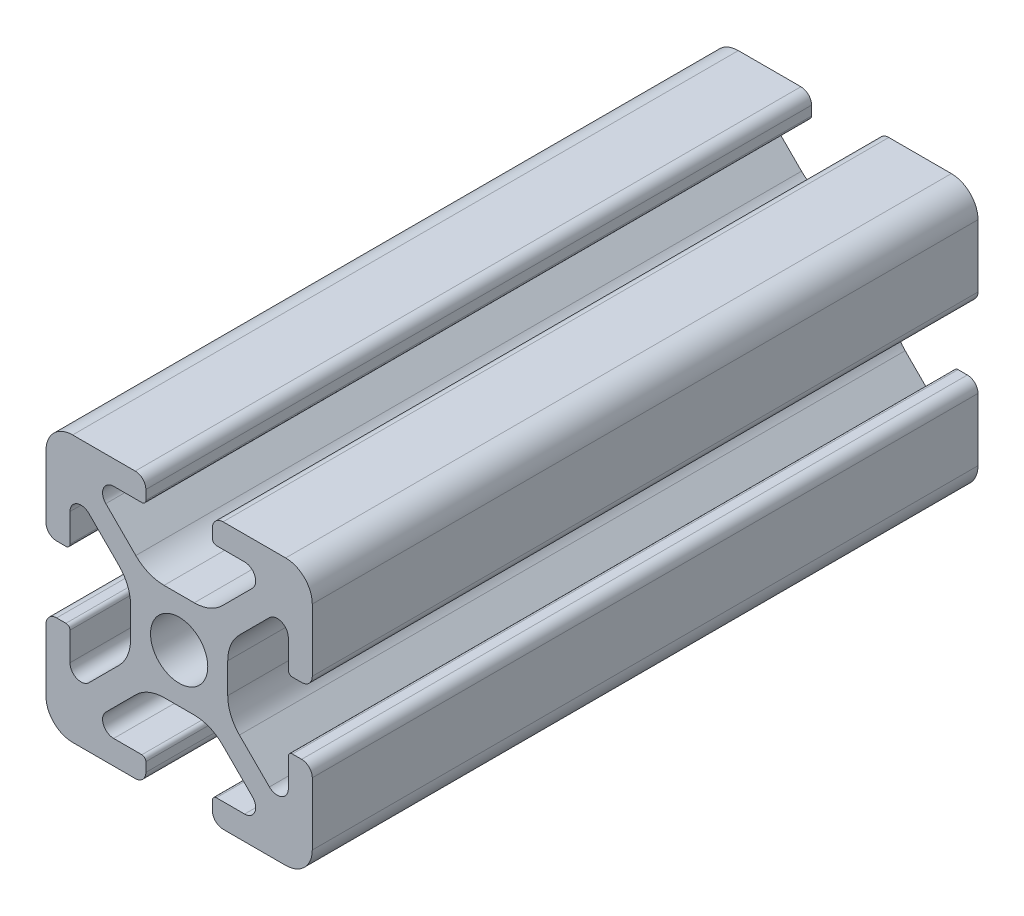
from build123d import *

# Parameters (mm, degrees)
SKETCH1_R           = 2.15
BOSS_EXTRUDE1_DEPTH = 50


with BuildPart() as part:
    # Sketch1 → Boss-Extrude1 (new body)
    with BuildSketch(Plane(origin=(0, 0, 0), x_dir=(-1, 0, 0), z_dir=(0, 0, -1))):
        with BuildLine():
            Line((-12.499999997, 0.800000003), (-12.499999998, 1.500000003))
            ThreePointArc((-12.499999998, 1.500000003), (-12.587867964, 1.712132039), (-12.8, 1.800000005))
            Line((-12.8, 1.800000005), (-14.9175884, 1.800000005))
            ThreePointArc((-14.9175884, 1.800000005), (-15.686636445, 2.313861481), (-15.506192291, 3.221015502))
            Line((-15.506192291, 3.221015502), (-13.255887451, 5.471320342))
            ThreePointArc((-13.255887451, 5.471320342), (-12.282617405, 6.121638595), (-11.134567109, 6.349999998))
            Line((-11.134567109, 6.349999998), (-8.865432906, 6.349999998))
            ThreePointArc((-8.865432906, 6.349999998), (-7.717382611, 6.121638596), (-6.744112565, 5.471320342))
            Line((-6.744112565, 5.471320342), (-4.493807727, 3.221015504))
            ThreePointArc((-4.493807727, 3.221015504), (-4.313363573, 2.313861481), (-5.082411619, 1.800000005))
            Line((-5.082411619, 1.800000005), (-7.20000001, 1.800000005))
            ThreePointArc((-7.20000001, 1.800000005), (-7.412132045, 1.71213204), (-7.50000001, 1.500000005))
            Line((-7.50000001, 1.500000005), (-7.50000001, 0.8))
            ThreePointArc((-7.50000001, 0.8), (-7.265685435, 0.234314575), (-6.70000001, 0))
            Line((-6.70000001, 0), (-2, 0))
            ThreePointArc((-2, 0), (-0.585786438, 0.585786438), (0, 2))
            Line((0, 2), (0, 6.699999998))
            ThreePointArc((0, 6.699999998), (-0.234314576, 7.265685424), (-0.800000003, 7.5))
            Line((-0.800000003, 7.5), (-1.500000007, 7.5))
            ThreePointArc((-1.500000007, 7.5), (-1.712132044, 7.412132033), (-1.80000001, 7.199999997))
            Line((-1.80000001, 7.199999997), (-1.80000001, 5.082411604))
            ThreePointArc((-1.80000001, 5.082411604), (-2.313861485, 4.313363559), (-3.221015507, 4.493807713))
            Line((-3.221015507, 4.493807713), (-5.471320347, 6.744112553))
            ThreePointArc((-5.471320347, 6.744112553), (-6.1216386, 7.717382599), (-6.350000003, 8.865432896))
            Line((-6.350000003, 8.865432896), (-6.350000003, 11.134567105))
            ThreePointArc((-6.350000003, 11.134567105), (-6.121638601, 12.2826174), (-5.471320347, 13.255887446))
            Line((-5.471320347, 13.255887446), (-3.221015511, 15.506192282))
            ThreePointArc((-3.221015511, 15.506192282), (-2.313861487, 15.686636436), (-1.80000001, 14.917588389))
            Line((-1.80000001, 14.917588389), (-1.80000001, 12.799999998))
            ThreePointArc((-1.80000001, 12.799999998), (-1.712132045, 12.587867963), (-1.50000001, 12.499999997))
            Line((-1.50000001, 12.499999997), (-0.8, 12.499999997))
            ThreePointArc((-0.8, 12.499999997), (-0.234314575, 12.734314573), (0, 13.299999998))
            Line((0, 13.299999998), (0, 18))
            ThreePointArc((0, 18), (-0.585786438, 19.414213562), (-2, 20))
            Line((-2, 20), (-6.700000008, 20))
            ThreePointArc((-6.700000008, 20), (-7.265685435, 19.765685424), (-7.50000001, 19.199999998))
            Line((-7.50000001, 19.199999998), (-7.50000001, 18.500000005))
            ThreePointArc((-7.50000001, 18.500000005), (-7.412132044, 18.287867969), (-7.200000008, 18.200000003))
            Line((-7.200000008, 18.200000003), (-5.082411595, 18.200000003))
            ThreePointArc((-5.082411595, 18.200000003), (-4.313363547, 17.686138525), (-4.493807702, 16.7789845))
            Line((-4.493807702, 16.7789845), (-6.744112543, 14.528679659))
            ThreePointArc((-6.744112543, 14.528679659), (-7.717382589, 13.878361405), (-8.865432885, 13.650000003))
            Line((-8.865432885, 13.650000003), (-11.134567111, 13.650000003))
            ThreePointArc((-11.134567111, 13.650000003), (-12.282617406, 13.878361405), (-13.255887452, 14.528679658))
            Line((-13.255887452, 14.528679658), (-15.506192292, 16.778984498))
            ThreePointArc((-15.506192292, 16.778984498), (-15.686636447, 17.686138525), (-14.917588397, 18.200000002))
            Line((-14.917588397, 18.200000002), (-12.799999998, 18.200000003))
            ThreePointArc((-12.799999998, 18.200000003), (-12.587867963, 18.287867968), (-12.499999997, 18.500000002))
            Line((-12.499999997, 18.500000002), (-12.499999997, 19.2))
            ThreePointArc((-12.499999997, 19.2), (-12.734314573, 19.765685425), (-13.299999998, 20))
            Line((-13.299999998, 20), (-18, 20))
            ThreePointArc((-18, 20), (-19.414213562, 19.414213562), (-20, 18))
            Line((-20, 18), (-20, 13.3))
            ThreePointArc((-20, 13.3), (-19.765685424, 12.734314573), (-19.199999998, 12.499999997))
            Line((-19.199999998, 12.499999997), (-18.500000003, 12.499999997))
            ThreePointArc((-18.500000003, 12.499999997), (-18.287867967, 12.587867964), (-18.2, 12.8))
            Line((-18.2, 12.8), (-18.2, 14.91758839))
            ThreePointArc((-18.2, 14.91758839), (-17.686138525, 15.686636435), (-16.778984504, 15.506192281))
            Line((-16.778984504, 15.506192281), (-14.528679657, 13.255887434))
            ThreePointArc((-14.528679657, 13.255887434), (-13.878361403, 12.282617388), (-13.65, 11.134567091))
            Line((-13.65, 11.134567091), (-13.65, 8.865432887))
            ThreePointArc((-13.65, 8.865432887), (-13.878361403, 7.717382591), (-14.528679656, 6.744112546))
            Line((-14.528679656, 6.744112546), (-16.778984496, 4.493807706))
            ThreePointArc((-16.778984496, 4.493807706), (-17.686138522, 4.313363551), (-18.2, 5.0824116))
            Line((-18.2, 5.0824116), (-18.2, 7.2))
            ThreePointArc((-18.2, 7.2), (-18.287867966, 7.412132034), (-18.5, 7.5))
            Line((-18.5, 7.5), (-19.2, 7.5))
            ThreePointArc((-19.2, 7.5), (-19.765685425, 7.265685425), (-20, 6.7))
            Line((-20, 6.7), (-20, 2))
            ThreePointArc((-20, 2), (-19.414213562, 0.585786438), (-18, 0))
            Line((-18, 0), (-13.3, 0))
            ThreePointArc((-13.3, 0), (-12.734314573, 0.234314576), (-12.499999997, 0.800000003))
        make_face()
        with Locations((-10, 10)):
            Circle(SKETCH1_R, mode=Mode.SUBTRACT)
    extrude(amount=-BOSS_EXTRUDE1_DEPTH)


solid = part.part
